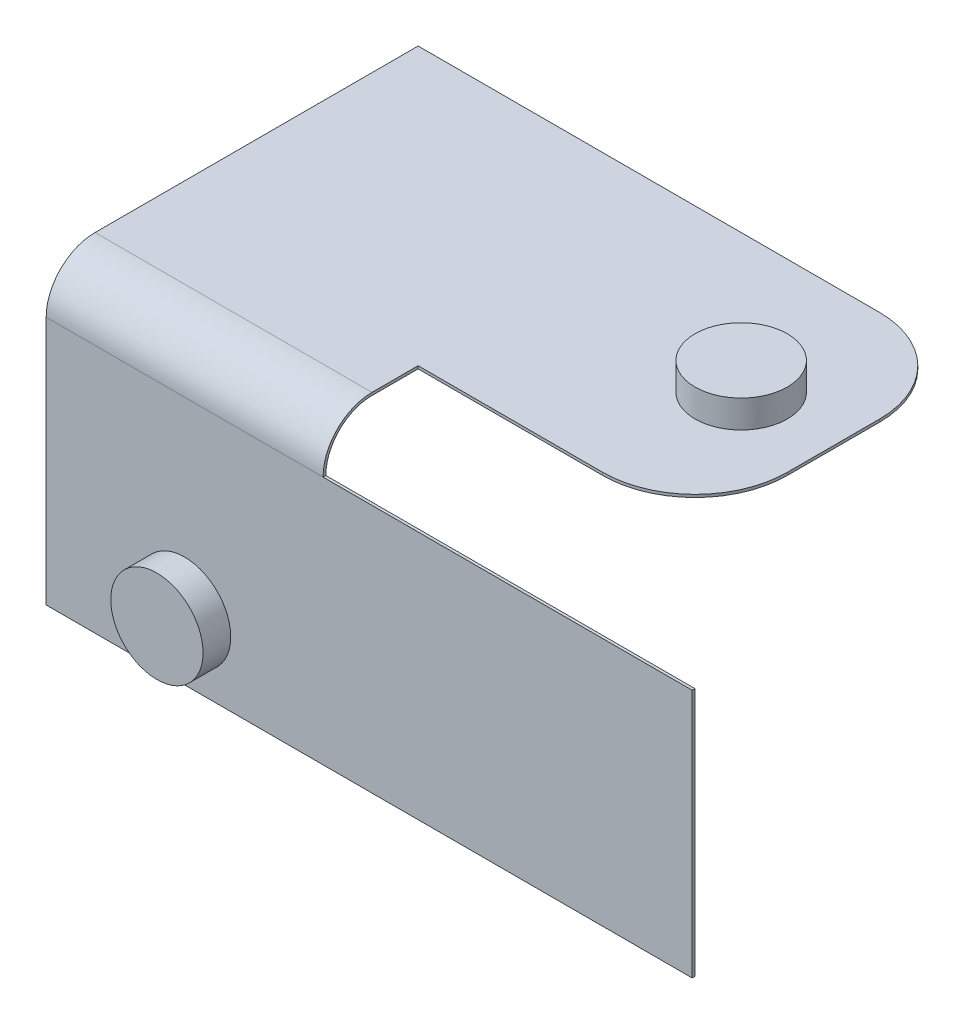
from build123d import *

# Parameters (mm, degrees)
SKETCH1_W           = 60
SKETCH1_H           = 30
BOSS_EXTRUDE1_DEPTH = 0.3
BOSS_EXTRUDE3_DEPTH = 30
SKETCH7_R           = 5
BOSS_EXTRUDE4_DEPTH = 3
SKETCH8_R           = 5
BOSS_EXTRUDE5_DEPTH = 3
SKETCH9_W           = 0.3
SKETCH9_H           = 27
BOSS_EXTRUDE6_DEPTH = 40
FILLET1_R           = 10


with BuildPart() as part:
    # Sketch1 → Boss-Extrude1 (new body)
    with BuildSketch(Plane(origin=(0, 0, 0), x_dir=(1, 0, 0), z_dir=(0, 1, 0))):
        with Locations((-33.606331541, -13.845258597)):
            Rectangle(SKETCH1_W, SKETCH1_H)
    extrude(amount=BOSS_EXTRUDE1_DEPTH)

    # Sketch6 → Boss-Extrude3 (add)
    with BuildSketch(Plane.ZY.offset(63.606331541)):
        with BuildLine():
            Line((28.845258597, 0.3), (33.845258597, 0.3))
            ThreePointArc((33.845258597, 0.3), (37.592924537, -1.25233406), (39.145258597, -5))
            Line((39.145258597, -5), (39.145258597, -32))
            Line((39.145258597, -32), (38.845258597, -32))
            Line((38.845258597, -32), (38.845258597, -5))
            ThreePointArc((38.845258597, -5), (37.380792503, -1.464466094), (33.845258597, 0))
            Line((33.845258597, 0), (28.845258597, 0))
            Line((28.845258597, 0), (28.845258597, 0.3))
        make_face()
    extrude(amount=-BOSS_EXTRUDE3_DEPTH)

    # Sketch7 → Boss-Extrude4 (add)
    with BuildSketch(Plane.XY.offset(39.145258597)):
        with Locations((-48.606331541, -25)):
            Circle(SKETCH7_R)
    extrude(amount=BOSS_EXTRUDE4_DEPTH)

    # Sketch8 → Boss-Extrude5 (add)
    with BuildSketch(Plane(origin=(0, 0.3, 0), x_dir=(1, 0, 0), z_dir=(0, 1, 0))):
        with Locations((-13.606331541, -13.845258597)):
            Circle(SKETCH8_R)
    extrude(amount=BOSS_EXTRUDE5_DEPTH)

    # Sketch9 → Boss-Extrude6 (add)
    with BuildSketch(Plane(origin=(-33.606331541, 0, 0), x_dir=(0, 0, -1), z_dir=(1, 0, 0))):
        with Locations((-38.995258597, -18.5)):
            Rectangle(SKETCH9_W, SKETCH9_H)
    extrude(amount=BOSS_EXTRUDE6_DEPTH)

    # Fillet1
    fillet1_edges = [part.edges().sort_by_distance(p)[0] for p in [
        (-3.606331541, 0.15, 28.845258597),
        (-3.606331541, 0.15, -1.154741403),
    ]]
    fillet(fillet1_edges, radius=FILLET1_R)


solid = part.part
